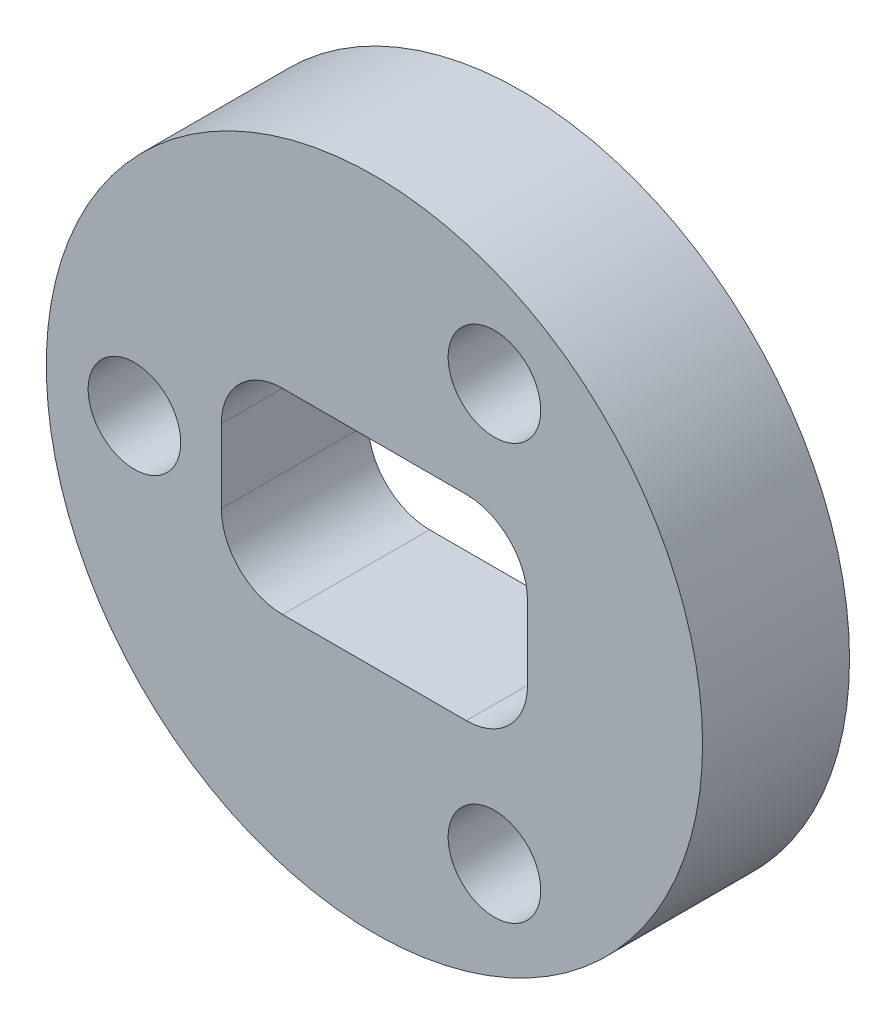
from build123d import *

# Parameters (mm, degrees)
SKETCH1_R            = 8.509
BOSS_EXTRUDE1_DEPTH  = 3.81
SKETCH3_W            = 7.9375
SKETCH3_H            = 5.08
CUT_EXTRUDE2_DEPTH   = 3.81
M2_CLEARANCE_HOLE1_D = 2.4
FILLET1_R            = 1.5875


with BuildPart() as part:
    # Sketch1 → Boss-Extrude1 (new body)
    with BuildSketch(Plane.XY):
        Circle(SKETCH1_R)
    extrude(amount=BOSS_EXTRUDE1_DEPTH)

    # Sketch3 → Cut-Extrude2 (cut)
    with BuildSketch(Plane.XY.offset(3.81)):
        Rectangle(SKETCH3_W, SKETCH3_H)
    extrude(amount=-CUT_EXTRUDE2_DEPTH, mode=Mode.SUBTRACT)

    # M2 Clearance Hole1 (through all)
    with Locations(Plane.XY.offset(3.81)):
        with Locations((-6.223, 0), (3.1115, 5.389276088), (3.1115, -5.389276088)):
            Hole(M2_CLEARANCE_HOLE1_D / 2)

    # Fillet1
    fillet1_edges = [part.edges().sort_by_distance(p)[0] for p in [
        (3.96875, 2.54, 1.905),
        (3.96875, -2.54, 1.905),
        (-3.96875, -2.54, 1.905),
        (-3.96875, 2.54, 1.905),
    ]]
    fillet(fillet1_edges, radius=FILLET1_R)


solid = part.part
